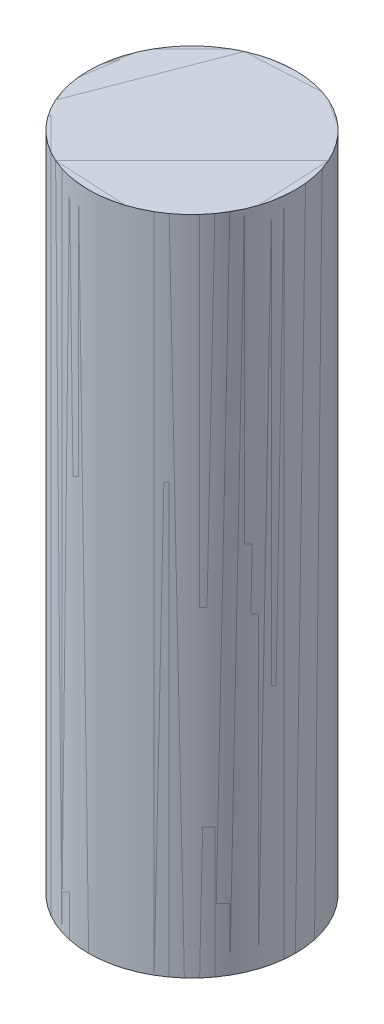
from build123d import *

# Parameters (mm, degrees)
SKETCH1_R           = 12.5
BOSS_EXTRUDE1_DEPTH = 80
SKETCH5_R           = 12.5
BOSS_EXTRUDE2_DEPTH = 80


with BuildPart() as part:
    # Sketch1 → Boss-Extrude1 (new body)
    with BuildSketch(Plane(origin=(0, 0, 0), x_dir=(1, 0, 0), z_dir=(0, 1, 0))):
        Circle(SKETCH1_R)
    extrude(amount=BOSS_EXTRUDE1_DEPTH)


with BuildPart() as body_2:
    # Sketch5 → Boss-Extrude2 (new body)
    with BuildSketch(Plane(origin=(0, 0, 0), x_dir=(-1, 0, 0), z_dir=(0, -1, 0))):
        Circle(SKETCH5_R)
    extrude(amount=-BOSS_EXTRUDE2_DEPTH)


solid = Compound([part.part, body_2.part])
